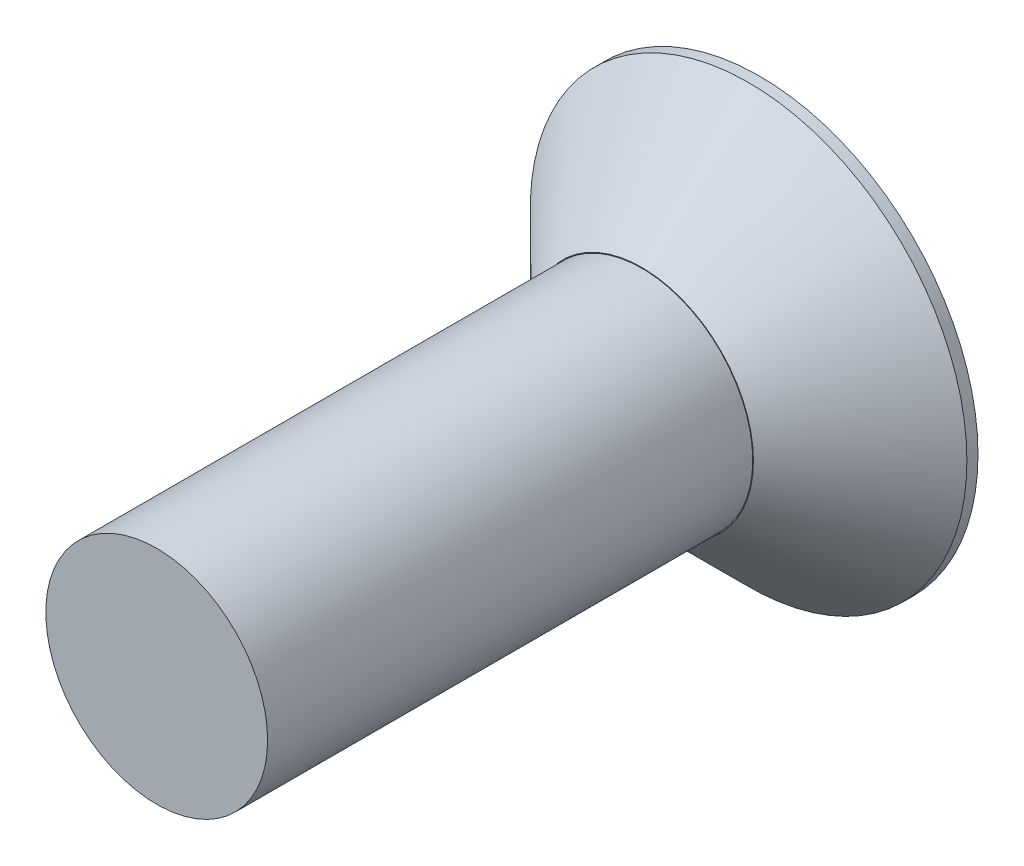
from build123d import *

# Parameters (mm, degrees)
SKETCH1_R         = 4.0005
EXTRUDE1_DEPTH    = 2.159
SKETCH2_R         = 2.032
EXTRUDE2_DEPTH    = 8.89
SKETCH3_W         = 5.08
SKETCH3_H         = 0.508
EXTRUDE3_DEPTH    = 1.016
CIRPATTERN1_COUNT = 2
CIRPATTERN1_ANGLE = 90
CHAMFER1_SIZE     = 1.9558


with BuildPart() as part:
    # Sketch1 → Extrude1 (new body)
    with BuildSketch(Plane.XY):
        Circle(SKETCH1_R)
    extrude(amount=EXTRUDE1_DEPTH)

    # Sketch2 → Extrude2 (add)
    with BuildSketch(Plane.XY.offset(2.159)):
        Circle(SKETCH2_R)
    extrude(amount=EXTRUDE2_DEPTH)

    # Sketch3 → Extrude3 (cut)
    with BuildSketch(Plane(origin=(0, 0, 0), x_dir=(-1, 0, 0), z_dir=(0, 0, -1))):
        Rectangle(SKETCH3_W, SKETCH3_H)
    extrude3 = extrude(amount=-EXTRUDE3_DEPTH, mode=Mode.SUBTRACT)

    # CirPattern1: Extrude3 ×2 about axis
    cirpattern1_axis = Axis((0, 0, 0), (0, 0, -1))
    for i in range(1, CIRPATTERN1_COUNT):
        add(extrude3.rotate(cirpattern1_axis, i * CIRPATTERN1_ANGLE / (CIRPATTERN1_COUNT - 1)), mode=Mode.SUBTRACT)

    # Chamfer1
    chamfer1_edges = [part.edges().sort_by_distance(p)[0] for p in [
        (-4.0005, 0, 2.159),
    ]]
    chamfer(chamfer1_edges, length=CHAMFER1_SIZE)


solid = part.part
